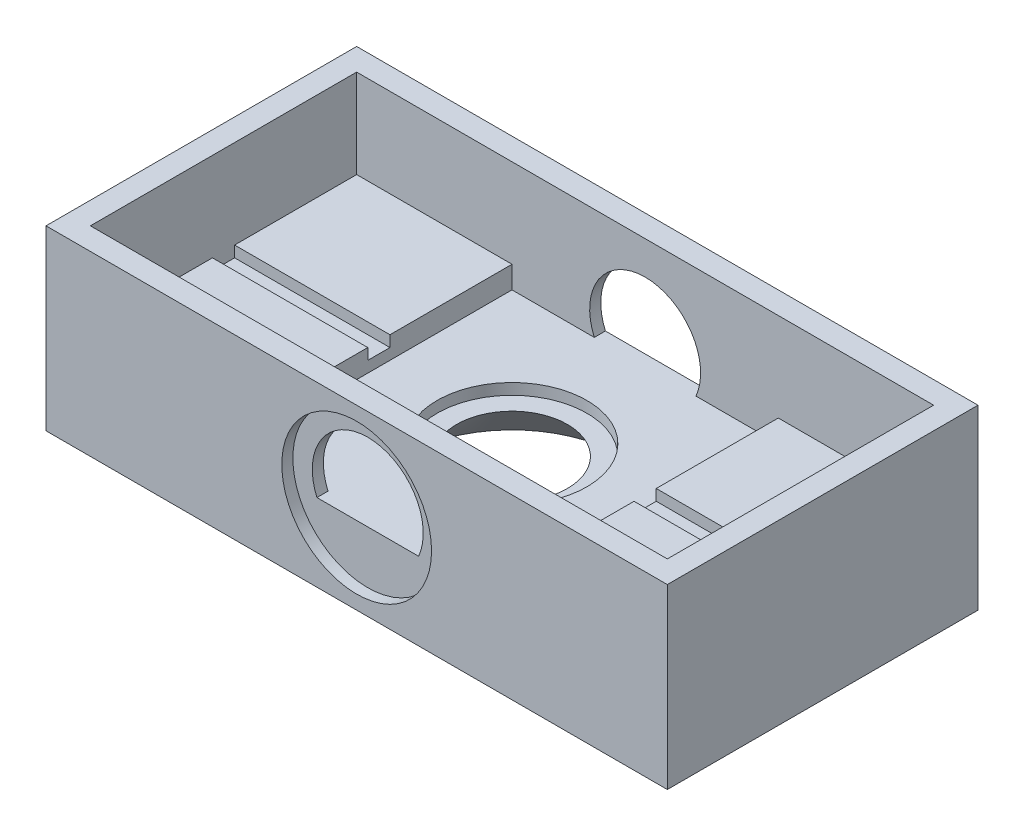
from build123d import *

# Parameters (mm, degrees)
SKETCH1_W           = 56
SKETCH1_H           = 28
BOSS_EXTRUDE1_DEPTH = 16
SKETCH2_W           = 52
SKETCH2_H           = 24
CUT_EXTRUDE1_DEPTH  = 8
SKETCH3_W           = 24
SKETCH3_H           = 24
CUT_EXTRUDE2_DEPTH  = 2
SKETCH4_W           = 52
SKETCH4_H           = 2
CUT_EXTRUDE3_DEPTH  = 1
SKETCH5_R           = 6.75
CUT_EXTRUDE4_DEPTH  = 1
CUT_EXTRUDE5_REACH  = 7
SKETCH6_R           = 5
SKETCH7_R           = 6.75
CUT_EXTRUDE6_DEPTH  = 1
SKETCH8_R           = 6.75
CUT_EXTRUDE7_DEPTH  = 1
CUT_EXTRUDE8_DEPTH  = 26


with BuildPart() as part:
    # Sketch1 → Boss-Extrude1 (new body)
    with BuildSketch(Plane(origin=(0, 0, 0), x_dir=(1, 0, 0), z_dir=(0, 1, 0))):
        Rectangle(SKETCH1_W, SKETCH1_H)
    extrude(amount=BOSS_EXTRUDE1_DEPTH)

    # Sketch2 → Cut-Extrude1 (cut)
    with BuildSketch(Plane(origin=(0, 16, 0), x_dir=(1, 0, 0), z_dir=(0, 1, 0))):
        Rectangle(SKETCH2_W, SKETCH2_H)
    extrude(amount=-CUT_EXTRUDE1_DEPTH, mode=Mode.SUBTRACT)

    # Sketch3 → Cut-Extrude2 (cut)
    with BuildSketch(Plane(origin=(0, 8, 0), x_dir=(1, 0, 0), z_dir=(0, 1, 0))):
        Rectangle(SKETCH3_W, SKETCH3_H)
    extrude(amount=-CUT_EXTRUDE2_DEPTH, mode=Mode.SUBTRACT)

    # Sketch4 → Cut-Extrude3 (cut)
    with BuildSketch(Plane(origin=(0, 8, 0), x_dir=(1, 0, 0), z_dir=(0, 1, 0))):
        Rectangle(SKETCH4_W, SKETCH4_H)
    extrude(amount=-CUT_EXTRUDE3_DEPTH, mode=Mode.SUBTRACT)

    # Sketch5 → Cut-Extrude4 (cut)
    with BuildSketch(Plane(origin=(0, 6, 0), x_dir=(1, 0, 0), z_dir=(0, 1, 0))):
        Circle(SKETCH5_R)
    extrude(amount=-CUT_EXTRUDE4_DEPTH, mode=Mode.SUBTRACT)

    # Sketch6 → Cut-Extrude5 (cut, up to next)
    with BuildSketch(Plane(origin=(0, 5, 0), x_dir=(1, 0, 0), z_dir=(0, 1, 0)), mode=Mode.PRIVATE) as cut_extrude5_sk1:
        Circle(SKETCH6_R)
    cut_extrude5_tool1 = extrude(cut_extrude5_sk1.sketch, amount=-CUT_EXTRUDE5_REACH, mode=Mode.PRIVATE) & part.part
    add(cut_extrude5_tool1.solids().sort_by_distance((0, 5, 0))[0], mode=Mode.SUBTRACT)

    # Sketch7 → Cut-Extrude6 (cut)
    with BuildSketch(Plane.XY.offset(14)):
        with Locations((0, 8)):
            Circle(SKETCH7_R)
    extrude(amount=-CUT_EXTRUDE6_DEPTH, mode=Mode.SUBTRACT)

    # Sketch8 → Cut-Extrude7 (cut)
    with BuildSketch(Plane(origin=(0, 0, -14), x_dir=(-1, 0, 0), z_dir=(0, 0, -1))):
        with Locations((0, 8)):
            Circle(SKETCH8_R)
    extrude(amount=-CUT_EXTRUDE7_DEPTH, mode=Mode.SUBTRACT)

    # Sketch9 → Cut-Extrude8 (cut)
    with BuildSketch(Plane.XY.offset(13)):
        with BuildLine():
            Line((-4.582575695, 6), (4.582575695, 6))
            ThreePointArc((4.582575695, 6), (0, 13), (-4.582575695, 6))
        make_face()
    extrude(amount=-CUT_EXTRUDE8_DEPTH, mode=Mode.SUBTRACT)

    # Sketch11 → Cut-Revolve2 (revolve, cut)
    with BuildSketch(Plane(origin=(0, 0, 0), x_dir=(0, 0, -1), z_dir=(1, 0, 0))):
        Polygon((0, 0), (-10, 0), (0, 10), align=None)
    revolve(axis=Axis((0, 10, 0), (0, -1, 0)), mode=Mode.SUBTRACT)


solid = part.part
